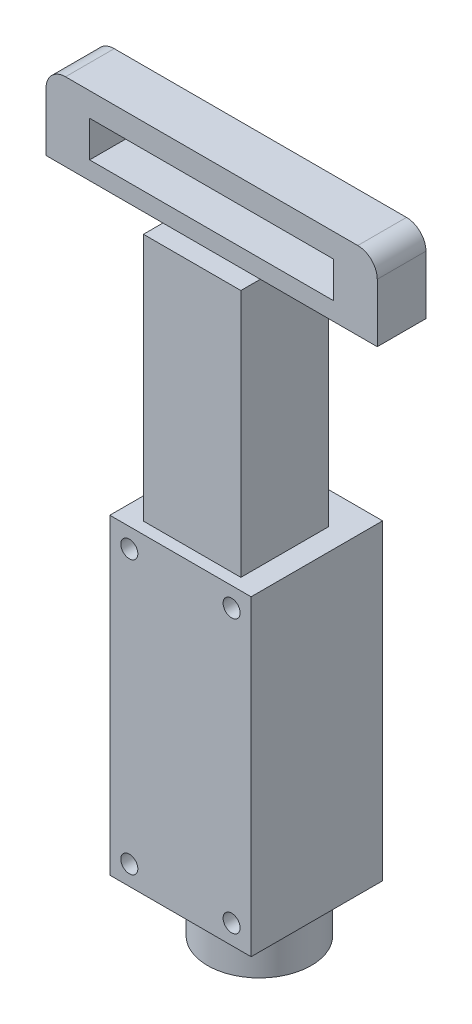
from build123d import *

# Parameters (mm, degrees)
SKETCH_1_W                  = 29
SKETCH_1_H                  = 64
EXTRUDE_1_DEPTH             = 27
SKETCH_2_W                  = 20
SKETCH_2_H                  = 18
EXTRUDE_2_DEPTH             = 51
SKETCH_3_W                  = 44
SKETCH_3_H                  = 10
EXTRUDE_3_DEPTH             = 16
SKETCH_4_W                  = 10
SKETCH_4_H                  = 16
EXTRUDE_4_DEPTH             = 24
SKETCH_5_W                  = 50.1
SKETCH_5_H                  = 7.4
CUT_EXTRUDE_1_DEPTH         = 21.6
SKETCH_6_W                  = 10.65
SKETCH_6_H                  = 11.6
HOLE_WIZARD_3_5_3_5_1_D     = 3.5
HOLE_WIZARD_3_5_3_5_1_DEPTH = 27
FILLET_1_R                  = 4


with BuildPart() as part:
    # 草图1 → 凸台-拉伸1 (new body)
    with BuildSketch(Plane.XY.offset(13.5)):
        Rectangle(SKETCH_1_W, SKETCH_1_H)
    extrude(amount=-EXTRUDE_1_DEPTH)

    # 草图2 → 凸台-拉伸2 (add)
    with BuildSketch(Plane(origin=(0, 32, 0), x_dir=(-1, 0, 0), z_dir=(0, 1, 0))):
        with Locations((0, 2.1)):
            Rectangle(SKETCH_2_W, SKETCH_2_H)
    extrude(amount=EXTRUDE_2_DEPTH)

    # 草图3 → 凸台-拉伸3 (add)
    with BuildSketch(Plane(origin=(0, 83, 0), x_dir=(-1, 0, 0), z_dir=(0, 1, 0))):
        with Locations((12, 2.1)):
            Rectangle(SKETCH_3_W, SKETCH_3_H)
    extrude(amount=EXTRUDE_3_DEPTH)

    # 草图4 → 凸台-拉伸4 (add)
    with BuildSketch(Plane(origin=(10, 0, 0), x_dir=(0, 0, -1), z_dir=(1, 0, 0))):
        with Locations((-2.1, 91)):
            Rectangle(SKETCH_4_W, SKETCH_4_H)
    extrude(amount=EXTRUDE_4_DEPTH)

    # 草图5 → 切除-拉伸1 (cut, through all)
    with BuildSketch(Plane.XY.offset(7.1)):
        with Locations((0, 90.4)):
            Rectangle(SKETCH_5_W, SKETCH_5_H)
    extrude(amount=-CUT_EXTRUDE_1_DEPTH, mode=Mode.SUBTRACT)

    # 草图6 → 旋转1 (revolve)
    with BuildSketch(Plane.XY.offset(-2.7)):
        with Locations((5.325, -37.8)):
            Rectangle(SKETCH_6_W, SKETCH_6_H)
    revolve(axis=Axis((0, -32, -2.7), (0, -1, 0)))

    # Ø3.5 (3.5) 直径孔1
    with Locations(Plane.XY.offset(13.5)):
        with Locations((-10.5, -28), (10.5, -28), (-10.5, 28), (10.5, 28)):
            Hole(HOLE_WIZARD_3_5_3_5_1_D / 2, depth=HOLE_WIZARD_3_5_3_5_1_DEPTH)

    # 圆角1
    fillet_1_edges = [part.edges().sort_by_distance(p)[0] for p in [
        (-34, 99, 2.1),
        (34, 99, 2.1),
    ]]
    fillet(fillet_1_edges, radius=FILLET_1_R)


solid = part.part
